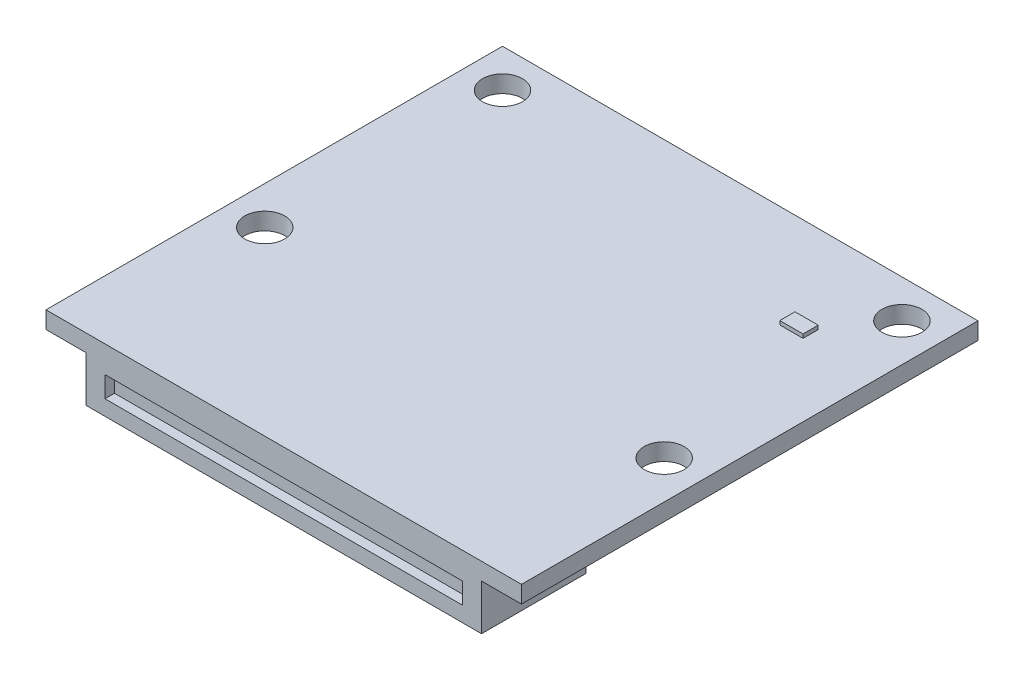
from build123d import *

# Parameters (mm, degrees)
SKIZZE1_W               = 25
SKIZZE1_H               = 24
PCB_DEPTH               = 0.9
SKIZZE2_R               = 1.05
MOUNTING_HOLES_DEPTH    = 1.9
SKIZZE3_W               = 20.8
SKIZZE3_H               = 5.5
CONNECTOR_CLOSED_DEPTH  = 2.4
ESQUISSE1_W             = 1.22
ESQUISSE1_H             = 0.8
STATUS_LED_DEPTH        = 0.2
ESQUISSE3_W             = 18.8
ESQUISSE3_H             = 1.1
ENL_V_MAT_EXTRU_1_DEPTH = 0.5


with BuildPart() as part:
    # Skizze1 → PCB (new body)
    with BuildSketch(Plane(origin=(0, 0, 0), x_dir=(1, 0, 0), z_dir=(0, 1, 0))):
        with Locations((0, 2.5)):
            Rectangle(SKIZZE1_W, SKIZZE1_H)
    extrude(amount=-PCB_DEPTH)

    # Skizze2 → Mounting_Holes (cut, through all)
    with BuildSketch(Plane(origin=(0, 0, 0), x_dir=(1, 0, 0), z_dir=(0, 1, 0))):
        with Locations((10.5, 12.5)):
            Circle(SKIZZE2_R)
        with Locations((10.5, 0)):
            Circle(SKIZZE2_R)
        with Locations((-10.5, 0)):
            Circle(SKIZZE2_R)
        with Locations((-10.5, 12.5)):
            Circle(SKIZZE2_R)
    extrude(amount=-MOUNTING_HOLES_DEPTH, mode=Mode.SUBTRACT)

    # Skizze3 → Connector_closed (add)
    with BuildSketch(Plane.XZ.offset(0.9)):
        with Locations((0, 6.75)):
            Rectangle(SKIZZE3_W, SKIZZE3_H)
    extrude(amount=CONNECTOR_CLOSED_DEPTH)

    # Esquisse1 → Status LED (add)
    with BuildSketch(Plane(origin=(0, 0, 0), x_dir=(1, 0, 0), z_dir=(0, 1, 0))):
        with Locations((8.09, 9.5)):
            Rectangle(ESQUISSE1_W, ESQUISSE1_H)
    extrude(amount=STATUS_LED_DEPTH)

    # Esquisse3 → Enlèv. mat.-Extru.1 (cut)
    with BuildSketch(Plane.XY.offset(9.5)):
        with Locations((0, -1.95)):
            Rectangle(ESQUISSE3_W, ESQUISSE3_H)
    extrude(amount=-ENL_V_MAT_EXTRU_1_DEPTH, mode=Mode.SUBTRACT)


solid = part.part
